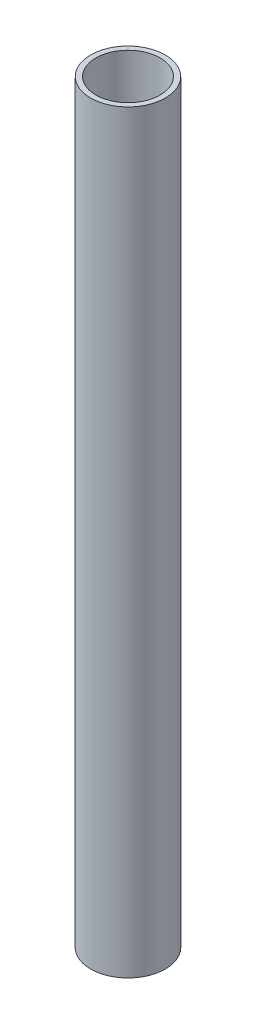
from build123d import *

# Parameters (mm, degrees)
SKETCH1_R           = 30.1625
SKETCH1_R_2         = 25.9969
BOSS_EXTRUDE1_DEPTH = 609.6


with BuildPart() as part:
    # Sketch1 → Boss-Extrude1 (new body)
    with BuildSketch(Plane(origin=(0, 0, 0), x_dir=(1, 0, 0), z_dir=(0, 1, 0))):
        Circle(SKETCH1_R)
        Circle(SKETCH1_R_2, mode=Mode.SUBTRACT)
    extrude(amount=BOSS_EXTRUDE1_DEPTH)


solid = part.part
